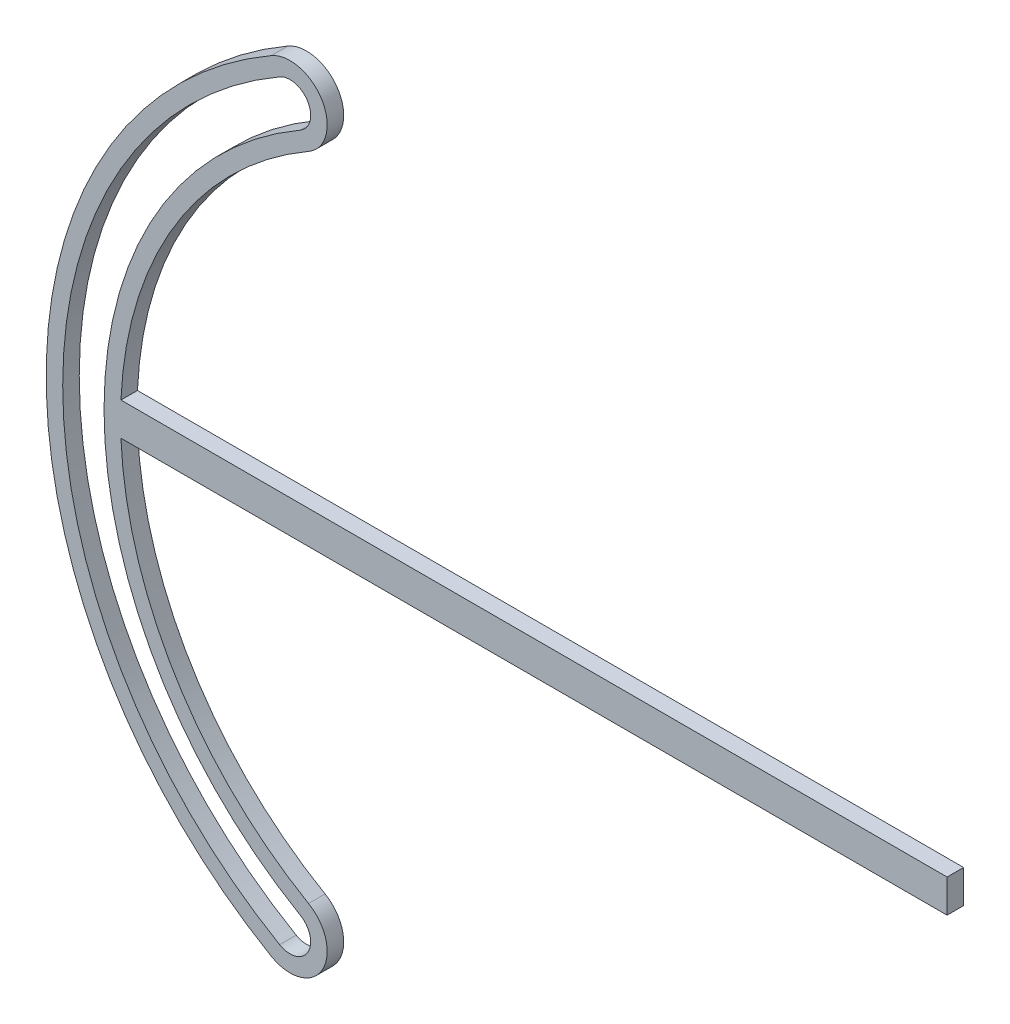
from build123d import *

# Parameters (mm, degrees)
EXTRUDE_1_DEPTH = 4


with BuildPart() as part:
    # 草图1 → 凸台-拉伸1 (new body)
    with BuildSketch(Plane.XY):
        with BuildLine():
            Line((-90.912045407, -4), (0, -4))
            Line((0, -4), (109, -4))
            Line((109, -4), (109, 4))
            Line((109, 4), (0, 4))
            Line((0, 4), (-90.912045407, 4))
            ThreePointArc((-90.912045407, 4), (-77.789024994, 47.221473828), (-45.5, 78.808311744))
            ThreePointArc((-45.5, 78.808311744), (-42.205771366, 91.102540378), (-54.5, 94.396769013))
            ThreePointArc((-54.5, 94.396769013), (-109, 0), (-54.5, -94.396769013))
            ThreePointArc((-54.5, -94.396769013), (-42.205771366, -91.102540378), (-45.5, -78.808311744))
            ThreePointArc((-45.5, -78.808311744), (-77.789024994, -47.221473828), (-90.912045407, -4))
        make_face()
        with BuildLine():
            ThreePointArc((-52.5, -90.932667397), (-105, 0), (-52.5, 90.932667397))
            ThreePointArc((-52.5, 90.932667397), (-45.669872981, 89.102540378), (-47.5, 82.27241336))
            ThreePointArc((-47.5, 82.27241336), (-95, 0), (-47.5, -82.27241336))
            ThreePointArc((-47.5, -82.27241336), (-45.669872981, -89.102540378), (-52.5, -90.932667397))
        make_face(mode=Mode.SUBTRACT)
    extrude(amount=EXTRUDE_1_DEPTH)


solid = part.part
